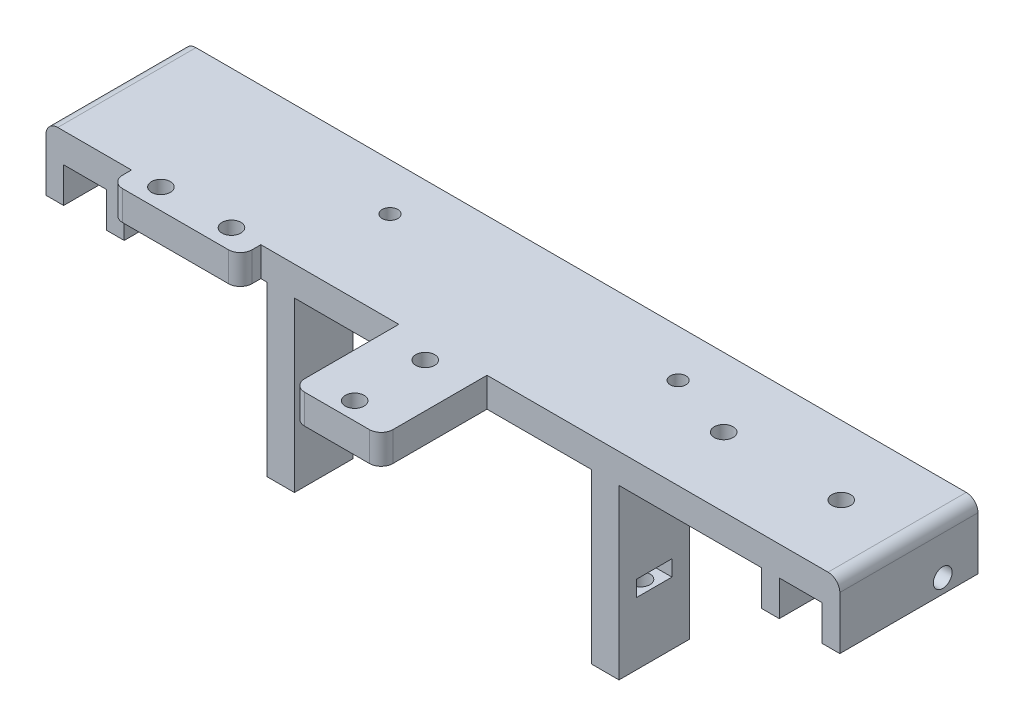
from build123d import *

# Parameters (mm, degrees)
SKETCH3_R           = 1.6
BOSS_EXTRUDE1_DEPTH = 5
SKETCH4_W           = 3
SKETCH4_H           = 23.5
BOSS_EXTRUDE2_DEPTH = 6
SKETCH5_R           = 1.6
CUT_EXTRUDE1_DEPTH  = 138.247950804
SKETCH6_W           = 4.7
SKETCH6_H           = 12
SKETCH6_R           = 1.6
BOSS_EXTRUDE3_DEPTH = 28.65
SKETCH8_W           = 6
SKETCH8_H           = 2.7
CUT_EXTRUDE3_DEPTH  = 105.371092741
FILLET1_R           = 2
CHAMFER1_SIZE       = 2
SKETCH9_R           = 1.333333333
CUT_EXTRUDE4_DEPTH  = 25
FILLET2_R           = 2


with BuildPart() as part:
    # Sketch3 → Boss-Extrude1 (new body)
    with BuildSketch(Plane(origin=(0, 0, 0), x_dir=(1, 0, 0), z_dir=(0, 1, 0))):
        Polygon((39.9, 17.5), (-95.1, 17.5), (-95.1, -6), (-80.560784084, -6), (-80.560784084, -9.5), (-58.560784084, -9.5), (-58.560784084, -6), (-35.1, -6), (-35.1, -24), (-20.1, -24), (-20.1, -6), (39.9, -6), align=None)
        with Locations((-63.560784084, -6)):
            Circle(SKETCH3_R, mode=Mode.SUBTRACT)
        with Locations((-75.560784084, -6)):
            Circle(SKETCH3_R, mode=Mode.SUBTRACT)
        with Locations((8.4, 5.75)):
            Circle(SKETCH3_R, mode=Mode.SUBTRACT)
        with Locations((28.4, 5.75)):
            Circle(SKETCH3_R, mode=Mode.SUBTRACT)
        with Locations((-27.6, -9)):
            Circle(SKETCH3_R, mode=Mode.SUBTRACT)
        with Locations((-27.6, -21)):
            Circle(SKETCH3_R, mode=Mode.SUBTRACT)
    extrude(amount=BOSS_EXTRUDE1_DEPTH)

    # Sketch4 → Boss-Extrude2 (add)
    with BuildSketch(Plane.XZ):
        with Locations((38.4, -5.75)):
            Rectangle(SKETCH4_W, SKETCH4_H)
        with Locations((28.1, -5.75)):
            Rectangle(SKETCH4_W, SKETCH4_H)
        with Locations((-93.6, -5.75)):
            Rectangle(SKETCH4_W, SKETCH4_H)
        with Locations((-83.3, -5.75)):
            Rectangle(SKETCH4_W, SKETCH4_H)
    extrude(amount=BOSS_EXTRUDE2_DEPTH)

    # Sketch5 → Cut-Extrude1 (cut, through all)
    with BuildSketch(Plane(origin=(39.9, 0, 0), x_dir=(0, 0, -1), z_dir=(1, 0, 0))):
        with Locations((11.5, -3.55)):
            Circle(SKETCH5_R)
    extrude(amount=-CUT_EXTRUDE1_DEPTH, mode=Mode.SUBTRACT)

    # Sketch6 → Boss-Extrude3 (add)
    # profile 1 of 2: a face of its own
    with BuildSketch(Plane.XZ):
        with Locations((-55.2, 0)):
            Rectangle(SKETCH6_W, SKETCH6_H)
        with Locations((-55.2, 0)):
            Circle(SKETCH6_R, mode=Mode.SUBTRACT)
    # profile 2 of 2: a face of its own
    with BuildSketch(Plane.XZ):
        Rectangle(SKETCH6_W, SKETCH6_H)
        Circle(SKETCH6_R, mode=Mode.SUBTRACT)
    extrude(amount=BOSS_EXTRUDE3_DEPTH)

    # Sketch8 → Cut-Extrude3 (cut, through all)
    with BuildSketch(Plane.ZY.offset(57.55)):
        with Locations((0, -16.65)):
            Rectangle(SKETCH8_W, SKETCH8_H)
    extrude(amount=-CUT_EXTRUDE3_DEPTH, mode=Mode.SUBTRACT)

    # Fillet1
    fillet1_edges = [part.edges().sort_by_distance(p)[0] for p in [
        (39.9, 5, -5.75),
        (-95.1, 5, -5.75),
    ]]
    fillet(fillet1_edges, radius=FILLET1_R)

    # Chamfer1
    chamfer1_edges = [part.edges().sort_by_distance(p)[0] for p in [
        (-2.35, -14.325, -6),
        (-52.85, -14.325, -6),
    ]]
    chamfer(chamfer1_edges, length=CHAMFER1_SIZE)

    # Sketch9 → Cut-Extrude4 (cut)
    with BuildSketch(Plane(origin=(0, 0, 0), x_dir=(1, 0, 0), z_dir=(0, 1, 0))):
        with Locations((-3.1, 9.5)):
            Circle(SKETCH9_R)
        with Locations((-52.1, 9.5)):
            Circle(SKETCH9_R)
    extrude(amount=CUT_EXTRUDE4_DEPTH, mode=Mode.SUBTRACT)

    # Fillet2
    fillet2_edges = [part.edges().sort_by_distance(p)[0] for p in [
        (-20.1, 2.5, 24),
        (-35.1, 2.5, 24),
        (-80.560784084, 2.5, 9.5),
        (-58.560784084, 2.5, 9.5),
    ]]
    fillet(fillet2_edges, radius=FILLET2_R)


solid = part.part
